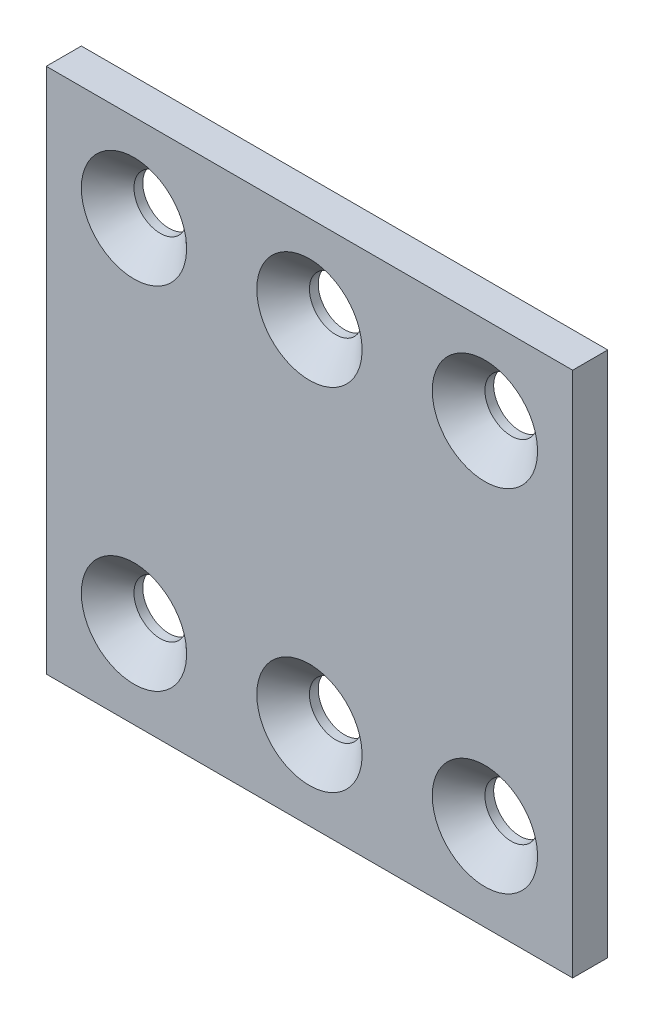
from build123d import *

# Parameters (mm, degrees)
SKETCH1_W           = 60
SKETCH1_H           = 60
BOSS_EXTRUDE1_DEPTH = 2
SKETCH2_R           = 3
CUT_EXTRUDE1_DEPTH  = 5
CHAMFER1_SIZE       = 3


with BuildPart() as part:
    # Sketch1 → Boss-Extrude1 (new body, symmetric)
    with BuildSketch(Plane.XY):
        Rectangle(SKETCH1_W, SKETCH1_H)
    extrude(amount=BOSS_EXTRUDE1_DEPTH, both=True)

    # Sketch2 → Cut-Extrude1 (cut, through all)
    with BuildSketch(Plane.XY.offset(2)):
        with Locations((0, 20)):
            Circle(SKETCH2_R)
        with Locations((0, -20)):
            Circle(SKETCH2_R)
        with Locations((20, -20)):
            Circle(SKETCH2_R)
        with Locations((-20, -20)):
            Circle(SKETCH2_R)
        with Locations((-20, 20)):
            Circle(SKETCH2_R)
        with Locations((20, 20)):
            Circle(SKETCH2_R)
    extrude(amount=-CUT_EXTRUDE1_DEPTH, mode=Mode.SUBTRACT)

    # Chamfer1
    chamfer1_edges = [part.edges().sort_by_distance(p)[0] for p in [
        (-3, -20, 2),
        (17, -20, 2),
        (-23, -20, 2),
        (-23, 20, 2),
        (17, 20, 2),
        (-3, 20, 2),
    ]]
    chamfer(chamfer1_edges, length=CHAMFER1_SIZE)


solid = part.part
